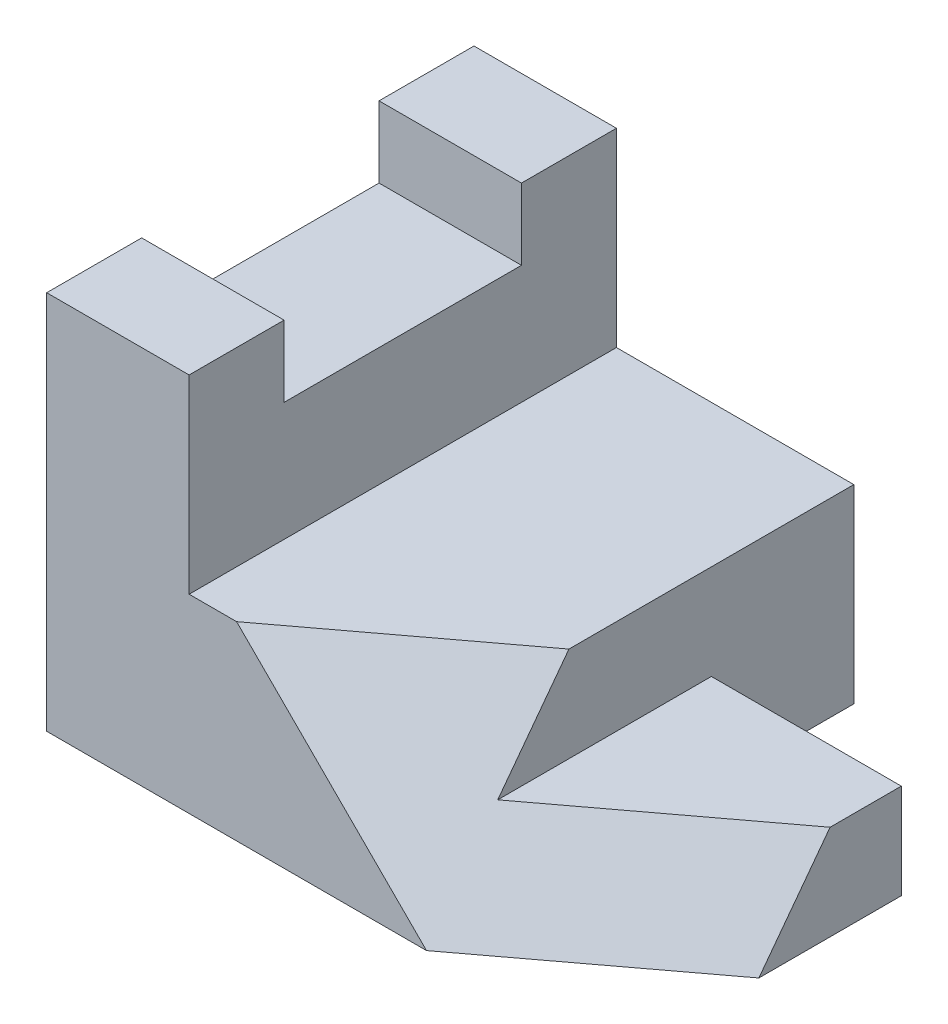
from build123d import *

# Parameters (mm, degrees)
SKETCH1_W           = 57.15
SKETCH1_H           = 25.4
BOSS_EXTRUDE1_DEPTH = 57.15
SKETCH2_W           = 25.4
SKETCH2_H           = 19.05
CUT_EXTRUDE1_DEPTH  = 85.719566807
CUT_EXTRUDE3_DEPTH  = 142.865944679
BOSS_EXTRUDE2_DEPTH = 19.05
SKETCH8_W           = 25.4
SKETCH8_H           = 76.2
CUT_EXTRUDE4_DEPTH  = 12.7


with BuildPart() as part:
    # Sketch1 → Boss-Extrude1 (new body)
    with BuildSketch(Plane(origin=(0, 0, 0), x_dir=(0, 0, -1), z_dir=(1, 0, 0))):
        with Locations((-28.575, 12.7)):
            Rectangle(SKETCH1_W, SKETCH1_H)
    extrude(amount=-BOSS_EXTRUDE1_DEPTH)

    # Sketch2 → Cut-Extrude1 (cut, through all)
    with BuildSketch(Plane(origin=(0, 25.4, 0), x_dir=(1, 0, 0), z_dir=(0, 1, 0))):
        with Locations((-12.7, -9.525)):
            Rectangle(SKETCH2_W, SKETCH2_H)
    extrude(amount=-CUT_EXTRUDE1_DEPTH, mode=Mode.SUBTRACT)

    # Sketch4 → Cut-Extrude3 (cut, through all, along a direction that is not the sketch's normal)
    with BuildSketch(Plane.XY.offset(57.15)):
        Polygon((-50.8, 25.4), (-25.4, 0), (0, 0), (0, 25.4), align=None)
    extrude(amount=-CUT_EXTRUDE3_DEPTH, dir=(-0.8, 0, 0.6), mode=Mode.SUBTRACT)

    # Sketch6 → Boss-Extrude2 (add)
    with BuildSketch(Plane.ZY.offset(57.15)):
        Polygon((0, 0), (0, 50.8), (12.7, 50.8), (12.7, 41.275), (44.45, 41.275), (44.45, 50.8), (57.15, 50.8), (57.15, 0), align=None)
    extrude(amount=BOSS_EXTRUDE2_DEPTH)

    # Sketch8 → Cut-Extrude4 (cut)
    with BuildSketch(Plane(origin=(0, 25.4, 0), x_dir=(1, 0, 0), z_dir=(0, 1, 0))):
        with Locations((-12.7, -57.15)):
            Rectangle(SKETCH8_W, SKETCH8_H)
    extrude(amount=-CUT_EXTRUDE4_DEPTH, mode=Mode.SUBTRACT)


solid = part.part
